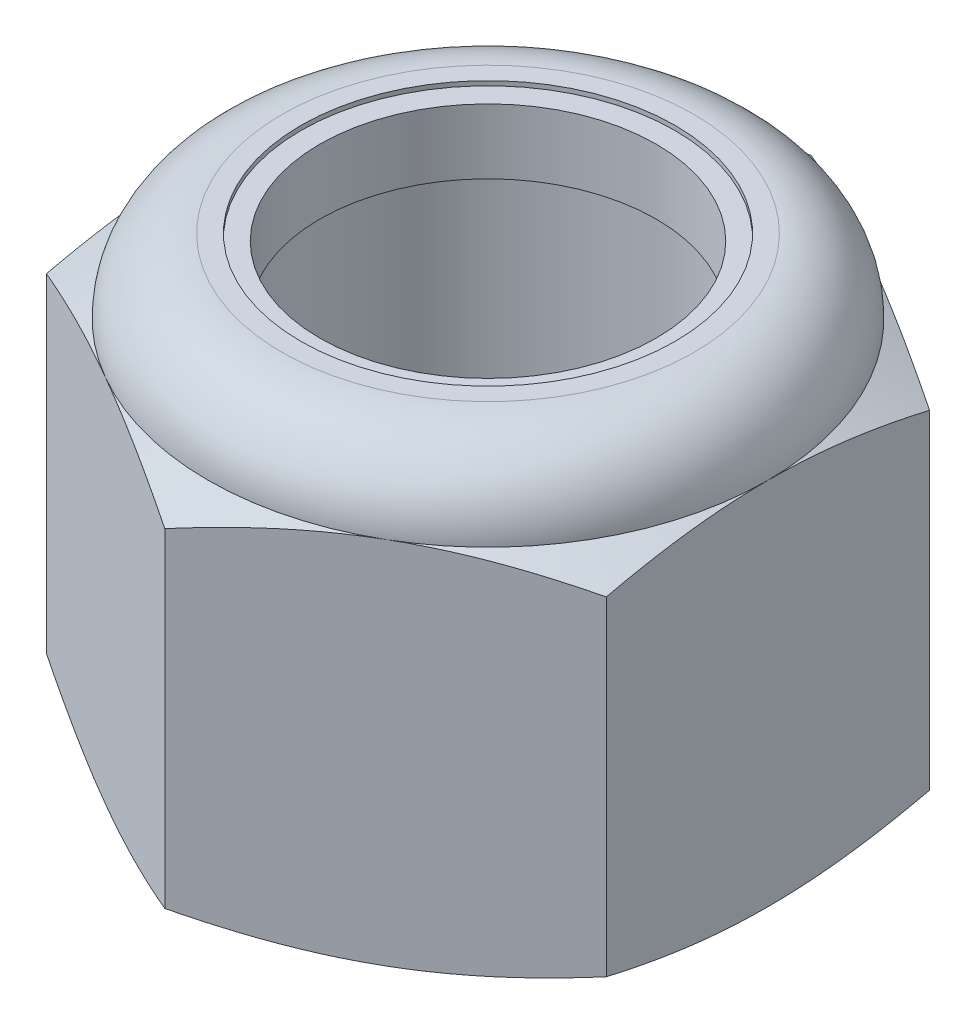
from build123d import *

# Parameters (mm, degrees)
EXTRUDE1_DEPTH = 15.08125
SKETCH2_W      = 6.35
SKETCH2_H      = 15.08125


with BuildPart() as part:
    # Sketch1 → Extrude1 (new body)
    with BuildSketch(Plane(origin=(0, 0, 0), x_dir=(1, 0, 0), z_dir=(0, 1, 0))):
        Polygon((0, 10.998522628), (-9.525, 5.499261314), (-9.525, -5.499261314), (0, -10.998522628), (9.525, -5.499261314), (9.525, 5.499261314), align=None)
    extrude(amount=EXTRUDE1_DEPTH)

    # Sketch4 → Cut-Revolve2 (revolve, cut)
    with BuildSketch(Plane(origin=(0, 0, 0), x_dir=(0, 0, -1), z_dir=(1, 0, 0))):
        Polygon((0, 15.08125), (6.35, 15.08125), (5.721290563, 14.788077975), (5.721290563, 0.293172025), (6.35, 0), (0, 0), align=None)
    revolve(axis=Axis((0, 15.08125, 0), (0, 1, 0)), mode=Mode.SUBTRACT)


with BuildPart() as body_2:
    # Sketch2 → Revolve1 (revolve)
    with BuildSketch(Plane(origin=(0, 0, 0), x_dir=(0, 0, -1), z_dir=(1, 0, 0))):
        with Locations((3.175, 7.540625)):
            Rectangle(SKETCH2_W, SKETCH2_H)
    revolve(axis=Axis((0, -6.35, 0), (0, 1, 0)))


with BuildPart() as part_1:
    add(part.part)

    # Combine1: cut body 2
    add(body_2.part, mode=Mode.SUBTRACT)

    # Sketch5 → Cut-Revolve3 (revolve, cut)
    with BuildSketch(Plane(origin=(0, 0, 0), x_dir=(0, 0, -1), z_dir=(1, 0, 0))):
        with BuildLine():
            Line((0, 0), (9.525, 0))
            Line((9.525, 0), (10.998522628, 0.687114886))
            Line((10.998522628, 0.687114886), (10.998522628, 11.880593447))
            Line((10.998522628, 11.880593447), (9.525, 12.567708333))
            ThreePointArc((9.525, 12.567708333), (8.788800691, 14.345050691), (7.011458333, 15.08125))
            Line((7.011458333, 15.08125), (7.011458333, 16.35125))
            Line((7.011458333, 16.35125), (12.268522628, 16.35125))
            Line((12.268522628, 16.35125), (12.268522628, -1.27))
            Line((12.268522628, -1.27), (0, -1.27))
            Line((0, -1.27), (0, 0))
        make_face()
    revolve(axis=Axis((0, 0, 0), (0, 1, 0)), mode=Mode.SUBTRACT)

    # Sketch6 → Cut-Revolve4 (revolve, cut)
    with BuildSketch(Plane(origin=(0, 0, 0), x_dir=(0, 0, -1), z_dir=(1, 0, 0))):
        with BuildLine():
            Line((0, 12.567708333), (9.3726, 12.567708333))
            ThreePointArc((9.3726, 12.567708333), (8.681037617, 14.237287617), (7.011458333, 14.92885))
            Line((7.011458333, 14.92885), (6.366374448, 14.92885))
            Line((6.366374448, 14.92885), (6.366374448, 16.35125))
            Line((6.366374448, 16.35125), (0, 16.35125))
            Line((0, 16.35125), (0, 12.567708333))
        make_face()
    revolve(axis=Axis((0, 16.35125, 0), (0, 1, 0)), mode=Mode.SUBTRACT)


with BuildPart() as body_2_2:
    # Sketch7 → Revolve2 (revolve)
    with BuildSketch(Plane(origin=(0, 0, 0), x_dir=(0, 0, -1), z_dir=(1, 0, 0))):
        with BuildLine():
            Line((5.721290563, 12.643908333), (9.295129058, 12.643908333))
            ThreePointArc((9.295129058, 12.643908333), (8.599986877, 14.210125907), (7.011458333, 14.85265))
            Line((7.011458333, 14.85265), (5.721290563, 14.85265))
            Line((5.721290563, 14.85265), (5.721290563, 12.643908333))
        make_face()
    revolve(axis=Axis((0, 12.643908333, 0), (0, 1, 0)))


solid = Compound([part_1.part, body_2_2.part])
